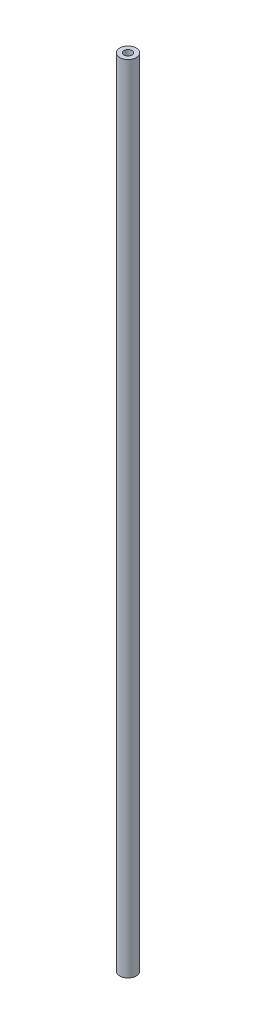
from build123d import *

# Parameters (mm, degrees)
SKETCH1_R           = 3.175
SKETCH1_R_2         = 1.524
BOSS_EXTRUDE1_DEPTH = 304.8


with BuildPart() as part:
    # Sketch1 → Boss-Extrude1 (new body)
    with BuildSketch(Plane(origin=(0, 0, 0), x_dir=(1, 0, 0), z_dir=(0, 1, 0))):
        Circle(SKETCH1_R)
        Circle(SKETCH1_R_2, mode=Mode.SUBTRACT)
    extrude(amount=BOSS_EXTRUDE1_DEPTH)


solid = part.part
